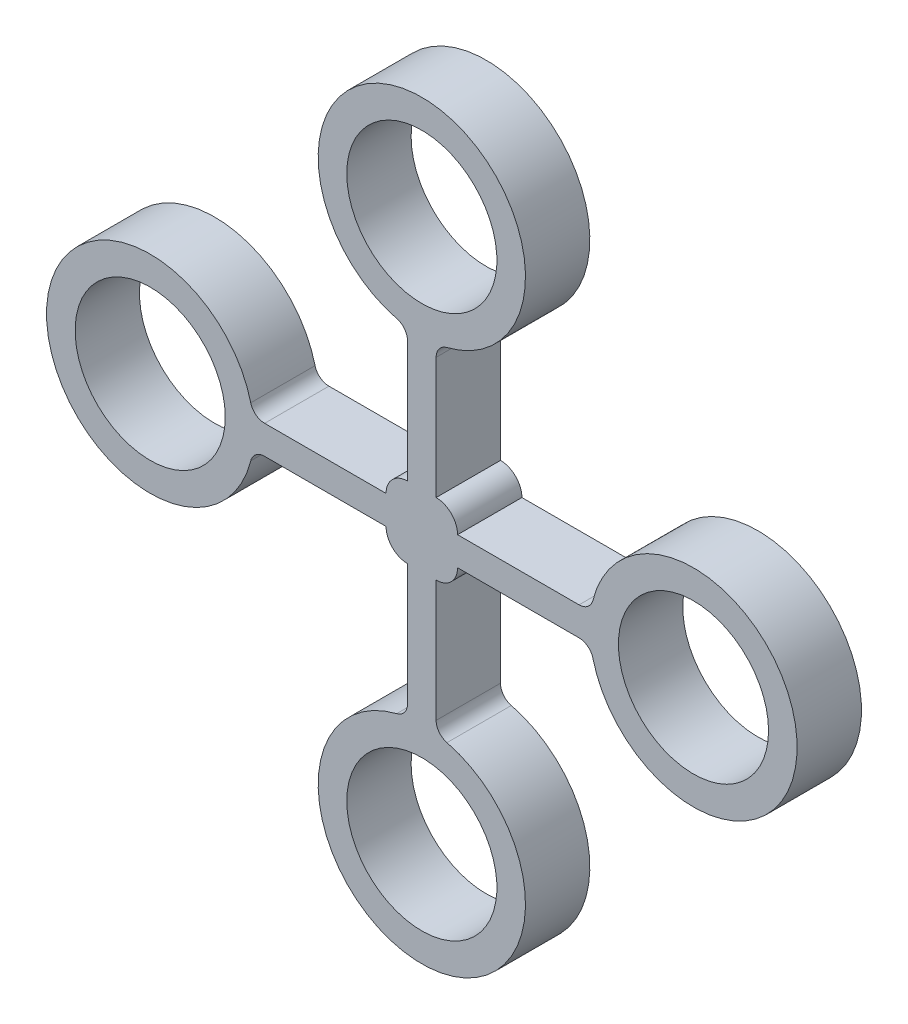
from build123d import *

# Parameters (mm, degrees)
SKETCH2_R           = 21
BOSS_EXTRUDE1_DEPTH = 18


with BuildPart() as part:
    # Sketch2 → Boss-Extrude1 (new body)
    with BuildSketch(Plane.XY):
        with BuildLine():
            Line((10, 4), (43.984378813, 4))
            ThreePointArc((43.984378813, 4), (46.446208632, 4.847319563), (47.865060169, 7.03030303))
            ThreePointArc((47.865060169, 7.03030303), (105, 0), (47.865060169, -7.03030303))
            ThreePointArc((47.865060169, -7.03030303), (46.446208632, -4.847319563), (43.984378813, -4))
            Line((43.984378813, -4), (10, -4))
            ThreePointArc((10, -4), (8.242640687, -8.242640687), (4, -10))
            Line((4, -10), (4, -43.984378813))
            ThreePointArc((4, -43.984378813), (4.847319563, -46.446208632), (7.03030303, -47.865060169))
            ThreePointArc((7.03030303, -47.865060169), (0, -105), (-7.03030303, -47.865060169))
            ThreePointArc((-7.03030303, -47.865060169), (-4.847319563, -46.446208632), (-4, -43.984378813))
            Line((-4, -43.984378813), (-4, -10))
            ThreePointArc((-4, -10), (-8.242640687, -8.242640687), (-10, -4))
            Line((-10, -4), (-43.984378813, -4))
            ThreePointArc((-43.984378813, -4), (-46.446208632, -4.847319563), (-47.865060169, -7.03030303))
            ThreePointArc((-47.865060169, -7.03030303), (-105, 0), (-47.865060169, 7.03030303))
            ThreePointArc((-47.865060169, 7.03030303), (-46.446208632, 4.847319563), (-43.984378813, 4))
            Line((-43.984378813, 4), (-10, 4))
            ThreePointArc((-10, 4), (-8.242640687, 8.242640687), (-4, 10))
            Line((-4, 10), (-4, 43.984378813))
            ThreePointArc((-4, 43.984378813), (-4.847319563, 46.446208632), (-7.03030303, 47.865060169))
            ThreePointArc((-7.03030303, 47.865060169), (0, 105), (7.03030303, 47.865060169))
            ThreePointArc((7.03030303, 47.865060169), (4.847319563, 46.446208632), (4, 43.984378813))
            Line((4, 43.984378813), (4, 10))
            ThreePointArc((4, 10), (8.242640687, 8.242640687), (10, 4))
        make_face()
        with Locations((76, 0)):
            Circle(SKETCH2_R, mode=Mode.SUBTRACT)
        with Locations((0, -76)):
            Circle(SKETCH2_R, mode=Mode.SUBTRACT)
        with Locations((-76, 0)):
            Circle(SKETCH2_R, mode=Mode.SUBTRACT)
        with Locations((0, 76)):
            Circle(SKETCH2_R, mode=Mode.SUBTRACT)
    extrude(amount=BOSS_EXTRUDE1_DEPTH)


solid = part.part
